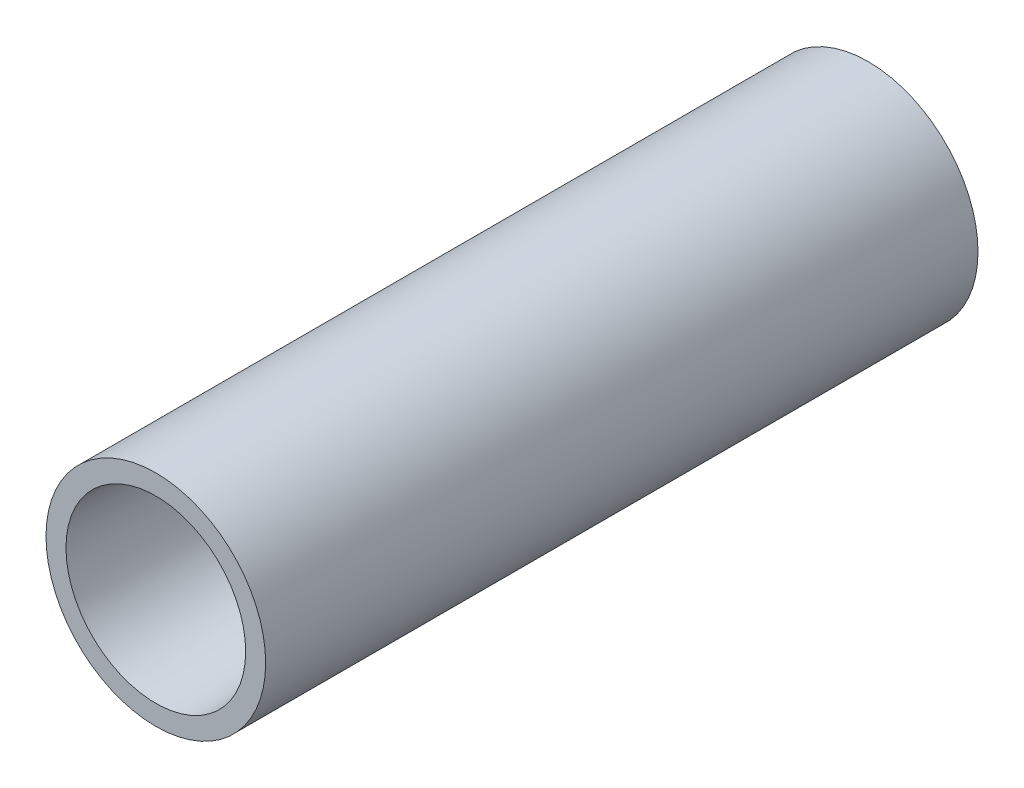
from build123d import *

# Parameters (mm, degrees)
SKETCH1_R           = 2.775
BOSS_EXTRUDE1_DEPTH = 18
SKETCH2_R           = 2.27
CUT_EXTRUDE1_DEPTH  = 5.68
CUT_EXTRUDE1_TAPER  = 3.074
SKETCH7_R           = 1
CUT_EXTRUDE2_DEPTH  = 19
SKETCH9_R           = 2.27
CUT_EXTRUDE3_DEPTH  = 5.68
CUT_EXTRUDE3_TAPER  = 3.074


with BuildPart() as part:
    # Sketch1 → Boss-Extrude1 (new body)
    with BuildSketch(Plane.XY):
        Circle(SKETCH1_R)
    extrude(amount=BOSS_EXTRUDE1_DEPTH)

    # Sketch2 → Cut-Extrude1 (cut)
    with BuildSketch(Plane.XY):
        Circle(SKETCH2_R)
    extrude(amount=CUT_EXTRUDE1_DEPTH, taper=CUT_EXTRUDE1_TAPER, mode=Mode.SUBTRACT)

    # Sketch7 → Cut-Extrude2 (cut, through all)
    with BuildSketch(Plane.XY):
        Circle(SKETCH7_R)
    extrude(amount=CUT_EXTRUDE2_DEPTH, mode=Mode.SUBTRACT)

    # Sketch9 → Cut-Extrude3 (cut)
    with BuildSketch(Plane.XY.offset(18)):
        Circle(SKETCH9_R)
    extrude(amount=-CUT_EXTRUDE3_DEPTH, taper=CUT_EXTRUDE3_TAPER, mode=Mode.SUBTRACT)


solid = part.part
